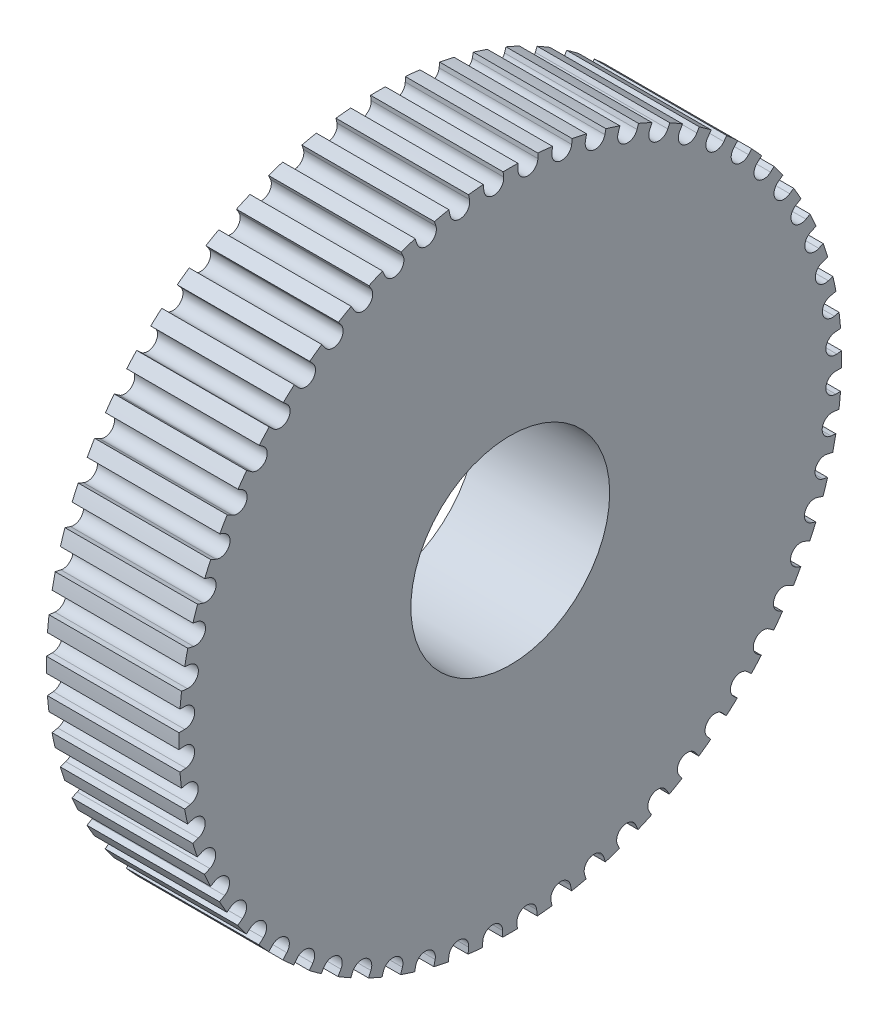
from build123d import *

# Parameters (mm, degrees)
SKETCH1_R           = 20
SKETCH1_R_2         = 6
BOSS_EXTRUDE1_DEPTH = 8
CUT_EXTRUDE1_DEPTH  = 10
CIRPATTERN1_COUNT   = 60


with BuildPart() as part:
    # Sketch1 → Boss-Extrude1 (new body)
    with BuildSketch(Plane(origin=(0, 0, 0), x_dir=(0, 0, -1), z_dir=(1, 0, 0))):
        Circle(SKETCH1_R)
        Circle(SKETCH1_R_2, mode=Mode.SUBTRACT)
    extrude(amount=BOSS_EXTRUDE1_DEPTH)

    # Sketch2 → Cut-Extrude1 (cut)
    with BuildSketch(Plane(origin=(8, 0, 0), x_dir=(0, 0, -1), z_dir=(1, 0, 0))):
        with BuildLine():
            Line((1.661545368, 20.667477008), (1.661545368, 19.642599207))
            ThreePointArc((1.661545368, 19.642599207), (1.061545368, 19.042599207), (0.461545368, 19.642599207))
            Line((0.461545368, 19.642599207), (0.461545368, 20.667477008))
            ThreePointArc((0.461545368, 20.667477008), (1.061545368, 21.267477008), (1.661545368, 20.667477008))
        make_face()
    cut_extrude1 = extrude(amount=-CUT_EXTRUDE1_DEPTH, mode=Mode.SUBTRACT)

    # CirPattern1: Cut-Extrude1 ×60 about axis
    cirpattern1_axis = Axis((0, 0, 0), (1, 0, 0))
    for i in range(1, CIRPATTERN1_COUNT):
        add(cut_extrude1.rotate(cirpattern1_axis, i * 360 / CIRPATTERN1_COUNT), mode=Mode.SUBTRACT)


solid = part.part
